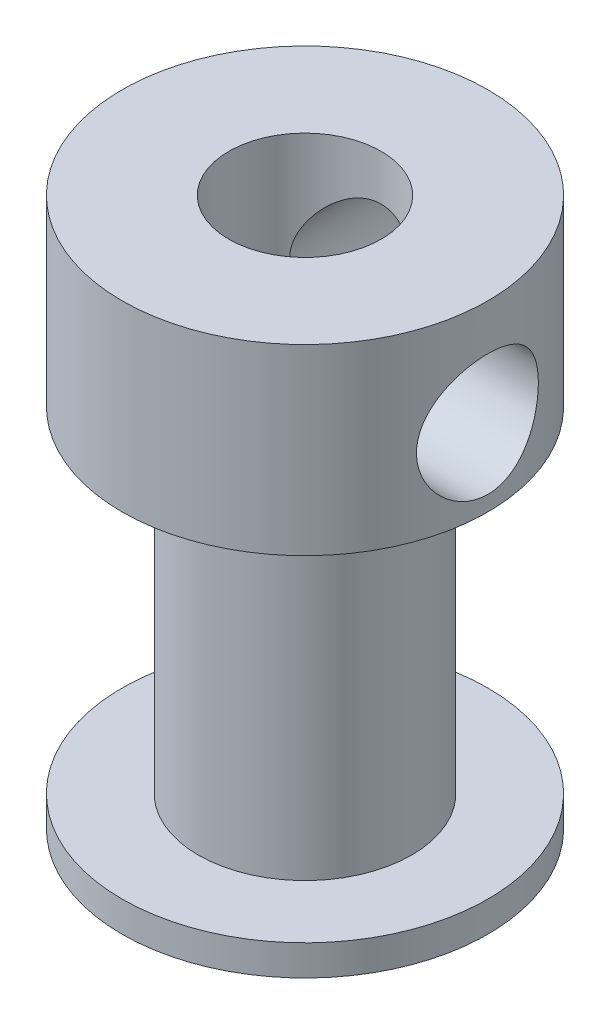
from build123d import *

# Parameters (mm, degrees)
SKETCH1_R           = 6
BOSS_EXTRUDE1_DEPTH = 1
SKETCH2_R           = 3.5
BOSS_EXTRUDE2_DEPTH = 11
SKETCH3_R           = 6
BOSS_EXTRUDE3_DEPTH = 2
SKETCH4_R           = 6
BOSS_EXTRUDE4_DEPTH = 4
SKETCH5_R           = 2.5
CUT_EXTRUDE1_DEPTH  = 19
SKETCH6_R           = 2
CUT_EXTRUDE2_DEPTH  = 7
CIRPATTERN1_COUNT   = 2
CIRPATTERN1_ANGLE   = 90


with BuildPart() as part:
    # Sketch1 → Boss-Extrude1 (new body)
    with BuildSketch(Plane(origin=(0, 0, 0), x_dir=(1, 0, 0), z_dir=(0, 1, 0))):
        Circle(SKETCH1_R)
    extrude(amount=BOSS_EXTRUDE1_DEPTH)

    # Sketch2 → Boss-Extrude2 (add)
    with BuildSketch(Plane(origin=(0, 1, 0), x_dir=(1, 0, 0), z_dir=(0, 1, 0))):
        Circle(SKETCH2_R)
    extrude(amount=BOSS_EXTRUDE2_DEPTH)

    # Sketch3 → Boss-Extrude3 (add)
    with BuildSketch(Plane(origin=(0, 12, 0), x_dir=(1, 0, 0), z_dir=(0, 1, 0))):
        Circle(SKETCH3_R)
    extrude(amount=BOSS_EXTRUDE3_DEPTH)

    # Sketch4 → Boss-Extrude4 (add)
    with BuildSketch(Plane(origin=(0, 14, 0), x_dir=(1, 0, 0), z_dir=(0, 1, 0))):
        Circle(SKETCH4_R)
    extrude(amount=BOSS_EXTRUDE4_DEPTH)

    # Sketch5 → Cut-Extrude1 (cut, through all)
    with BuildSketch(Plane(origin=(0, 18, 0), x_dir=(1, 0, 0), z_dir=(0, 1, 0))):
        Circle(SKETCH5_R)
    extrude(amount=-CUT_EXTRUDE1_DEPTH, mode=Mode.SUBTRACT)

    # Sketch6 → Cut-Extrude2 (cut, through all)
    with BuildSketch(Plane.XY):
        with Locations((0, 14.5)):
            Circle(SKETCH6_R)
    cut_extrude2 = extrude(amount=-CUT_EXTRUDE2_DEPTH, mode=Mode.SUBTRACT)

    # CirPattern1: Cut-Extrude2 ×2 about axis
    cirpattern1_axis = Axis((0, 14, 0), (0, -1, 0))
    for i in range(1, CIRPATTERN1_COUNT):
        add(cut_extrude2.rotate(cirpattern1_axis, i * CIRPATTERN1_ANGLE / (CIRPATTERN1_COUNT - 1)), mode=Mode.SUBTRACT)


solid = part.part
